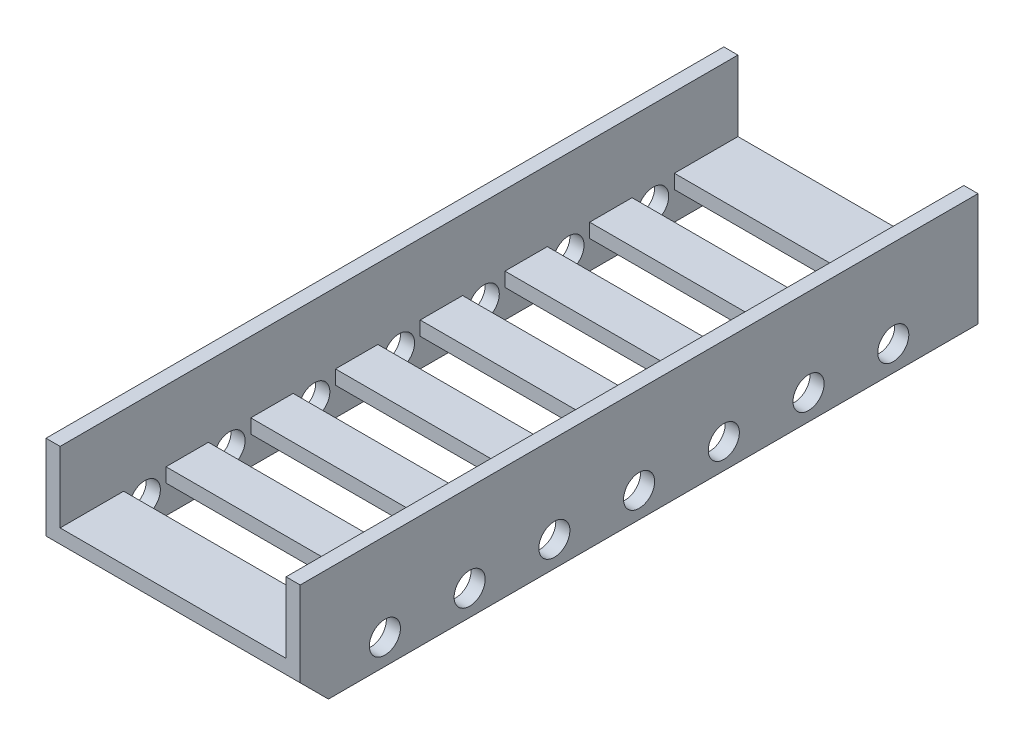
from build123d import *

# Parameters (mm, degrees)
SKETCH_1_W          = 5
SKETCH_1_H          = 10
EXTRUDE_1_DEPTH     = 240
SKETCH_3_R          = 5.5
CUT_EXTRUDE_1_DEPTH = 90
SKETCH_5_W          = 15
SKETCH_5_H          = 15
CUT_EXTRUDE_2_DEPTH = 80


with BuildPart() as part:
    # 草图1 → 凸台-拉伸1 (new body)
    with BuildSketch(Plane.XY):
        Polygon((0, -5), (0, 0), (-40, 0), (-40, 25), (-45, 25), (-45, -5), (-40, -5), align=None)
        Polygon((40, 25), (40, 0), (0, 0), (0, -5), (40, -5), (45, -5), (45, 25), align=None)
        with Locations((-42.5, -10)):
            Rectangle(SKETCH_1_W, SKETCH_1_H)
        with Locations((42.5, -10)):
            Rectangle(SKETCH_1_W, SKETCH_1_H)
    extrude(amount=EXTRUDE_1_DEPTH)

    # 草图3 → 切除-拉伸1 (cut, symmetric)
    with BuildSketch(Plane.ZY.offset(-40)):
        with Locations((30, -6)):
            Circle(SKETCH_3_R)
        with Locations((60, -6)):
            Circle(SKETCH_3_R)
        with Locations((90, -6)):
            Circle(SKETCH_3_R)
        with Locations((120, -6)):
            Circle(SKETCH_3_R)
        with Locations((150, -6)):
            Circle(SKETCH_3_R)
        with Locations((180, -6)):
            Circle(SKETCH_3_R)
        with Locations((210, -6)):
            Circle(SKETCH_3_R)
        Polygon((240, -5), (230, -15), (240, -15), align=None)
    extrude(amount=CUT_EXTRUDE_1_DEPTH, both=True, mode=Mode.SUBTRACT)

    # 草图5 → 切除-拉伸2 (cut)
    with BuildSketch(Plane(origin=(-40, 0, 0), x_dir=(0, 0, -1), z_dir=(1, 0, 0))):
        with Locations((-210, -5)):
            Rectangle(SKETCH_5_W, SKETCH_5_H)
        with Locations((-180, -5)):
            Rectangle(SKETCH_5_W, SKETCH_5_H)
        with Locations((-150, -5)):
            Rectangle(SKETCH_5_W, SKETCH_5_H)
        with Locations((-120, -5)):
            Rectangle(SKETCH_5_W, SKETCH_5_H)
        with Locations((-90, -5)):
            Rectangle(SKETCH_5_W, SKETCH_5_H)
        with Locations((-60, -5)):
            Rectangle(SKETCH_5_W, SKETCH_5_H)
        with Locations((-30, -5)):
            Rectangle(SKETCH_5_W, SKETCH_5_H)
    extrude(amount=CUT_EXTRUDE_2_DEPTH, mode=Mode.SUBTRACT)


solid = part.part
